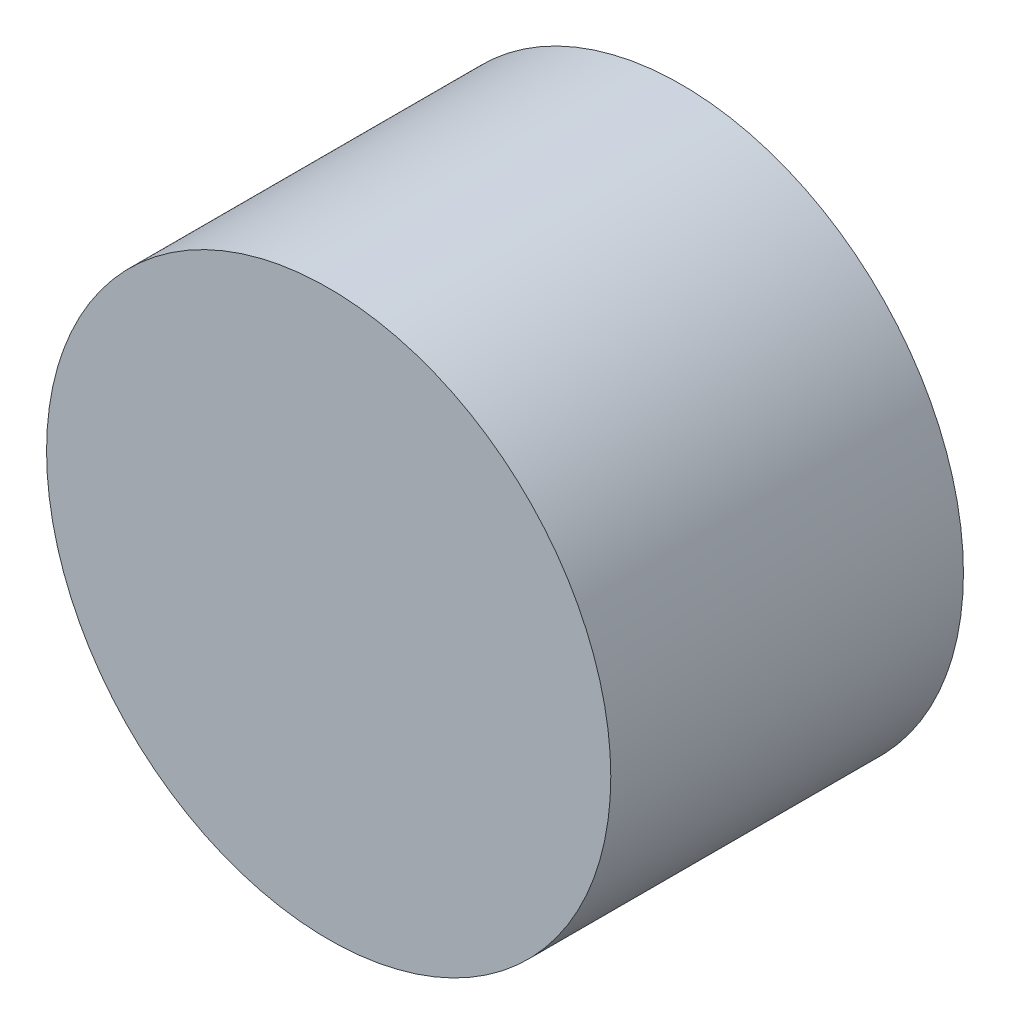
from build123d import *

# Parameters (mm, degrees)
SKETCH1_R           = 40.64
BOSS_EXTRUDE1_DEPTH = 50.8


with BuildPart() as part:
    # Sketch1 → Boss-Extrude1 (new body)
    with BuildSketch(Plane.XY):
        Circle(SKETCH1_R)
    extrude(amount=BOSS_EXTRUDE1_DEPTH)


solid = part.part
